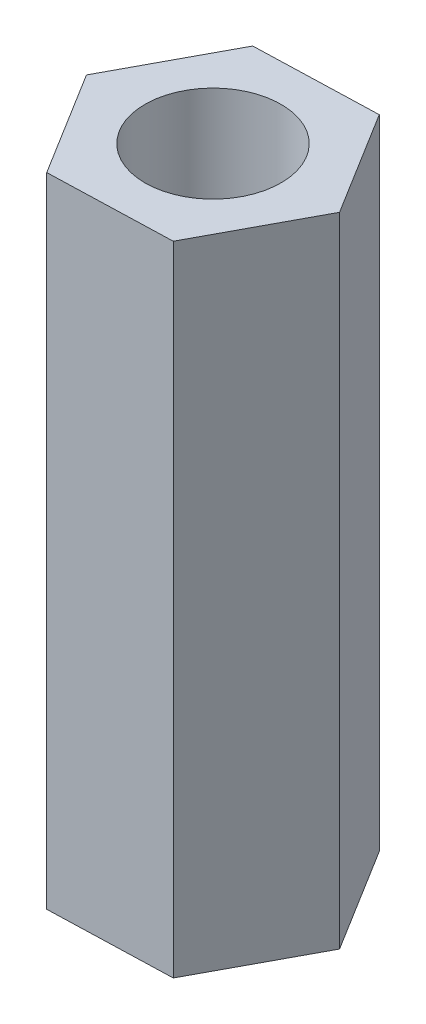
from build123d import *

# Parameters (mm, degrees)
SKETCH1_R           = 1.6
BOSS_EXTRUDE1_DEPTH = 15


with BuildPart() as part:
    # Sketch1 → Boss-Extrude1 (new body)
    with BuildSketch(Plane(origin=(0, 0, 0), x_dir=(1, 0, 0), z_dir=(0, 1, 0))):
        Polygon((1.365136707, 2.543567397), (-1.520225629, 2.454026766), (-2.885362336, -0.089540631), (-1.365136707, -2.543567397), (1.520225629, -2.454026766), (2.885362336, 0.089540631), align=None)
        Circle(SKETCH1_R, mode=Mode.SUBTRACT)
    extrude(amount=BOSS_EXTRUDE1_DEPTH)


solid = part.part
